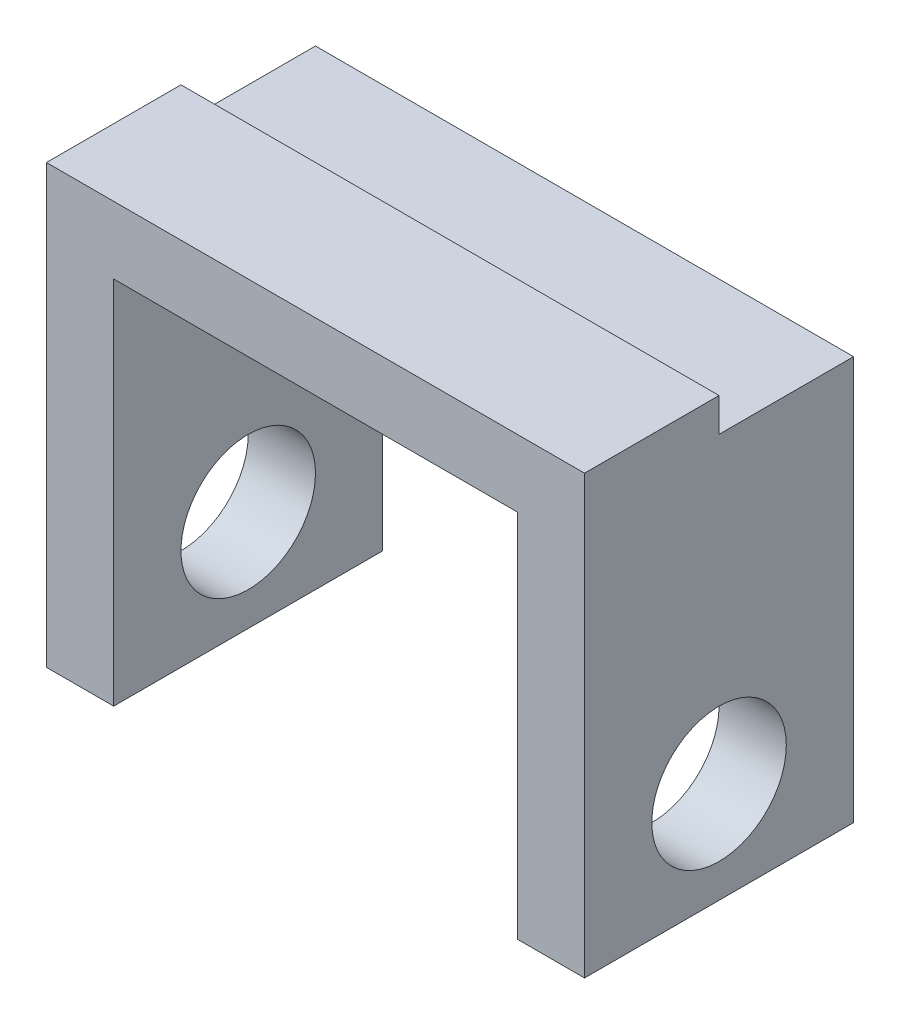
from build123d import *

# Parameters (mm, degrees)
CROQUIS1_W                 = 40
CROQUIS1_H                 = 65
CROQUIS1_R                 = 10
SALIENTE_EXTRUIR1_DEPTH    = 40
CROQUIS2_W                 = 60
CROQUIS2_H                 = 55
CORTAR_EXTRUIR1_DEPTH      = 21
CORTAR_EXTRUIR1_DEPTH_BACK = 21
CROQUIS3_W                 = 20
CROQUIS3_H                 = 5
CORTAR_EXTRUIR2_DEPTH      = 41
CORTAR_EXTRUIR2_DEPTH_BACK = 41


with BuildPart() as part:
    # Croquis1 → Saliente-Extruir1 (new body, symmetric)
    with BuildSketch(Plane(origin=(0, 0, 0), x_dir=(0, 0, -1), z_dir=(1, 0, 0))):
        with Locations((0, 17.5)):
            Rectangle(CROQUIS1_W, CROQUIS1_H)
        Circle(CROQUIS1_R, mode=Mode.SUBTRACT)
    extrude(amount=SALIENTE_EXTRUIR1_DEPTH, both=True)

    # Croquis2 → Cortar-Extruir1 (cut, two sides)
    with BuildSketch(Plane.XY) as cortar_extruir1_sk:
        with Locations((0, 12.5)):
            Rectangle(CROQUIS2_W, CROQUIS2_H)
    extrude(amount=CORTAR_EXTRUIR1_DEPTH, mode=Mode.SUBTRACT)
    extrude(cortar_extruir1_sk.sketch, amount=-CORTAR_EXTRUIR1_DEPTH_BACK, mode=Mode.SUBTRACT)

    # Croquis3 → Cortar-Extruir2 (cut, two sides)
    with BuildSketch(Plane(origin=(0, 0, 0), x_dir=(0, 0, -1), z_dir=(1, 0, 0))) as cortar_extruir2_sk:
        with Locations((10, 47.5)):
            Rectangle(CROQUIS3_W, CROQUIS3_H)
    extrude(amount=CORTAR_EXTRUIR2_DEPTH, mode=Mode.SUBTRACT)
    extrude(cortar_extruir2_sk.sketch, amount=-CORTAR_EXTRUIR2_DEPTH_BACK, mode=Mode.SUBTRACT)


solid = part.part
